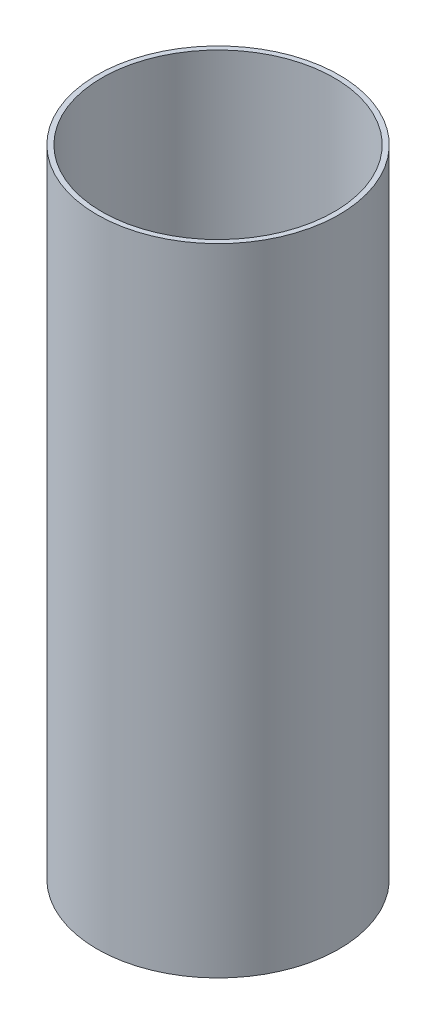
from build123d import *

# Parameters (mm, degrees)
SKETCH1_R           = 38.0746
SKETCH1_R_2         = 36.5125
BOSS_EXTRUDE1_DEPTH = 200


with BuildPart() as part:
    # Sketch1 → Boss-Extrude1 (new body)
    with BuildSketch(Plane(origin=(0, 0, 0), x_dir=(1, 0, 0), z_dir=(0, 1, 0))):
        Circle(SKETCH1_R)
        Circle(SKETCH1_R_2, mode=Mode.SUBTRACT)
    extrude(amount=BOSS_EXTRUDE1_DEPTH)


solid = part.part
